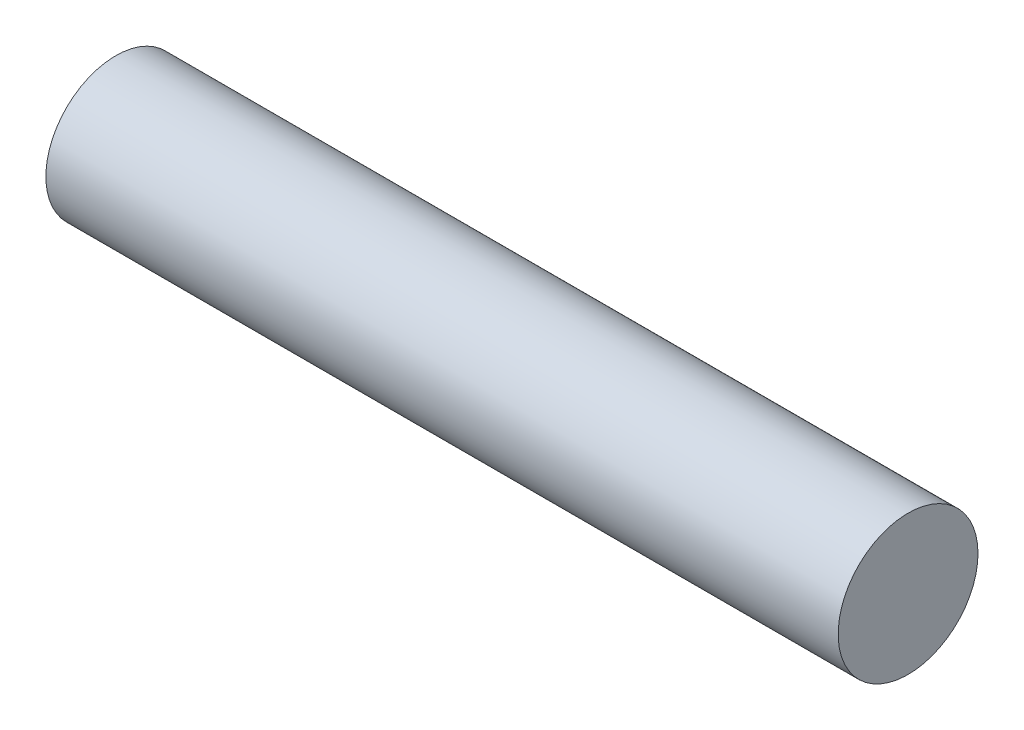
from build123d import *

# Parameters (mm, degrees)
SKETCH1_R           = 19.05
BOSS_EXTRUDE1_DEPTH = 107.95


with BuildPart() as part:
    # Sketch1 → Boss-Extrude1 (new body, symmetric)
    with BuildSketch(Plane(origin=(0, 0, 0), x_dir=(0, 0, -1), z_dir=(1, 0, 0))):
        Circle(SKETCH1_R)
    extrude(amount=BOSS_EXTRUDE1_DEPTH, both=True)


solid = part.part
